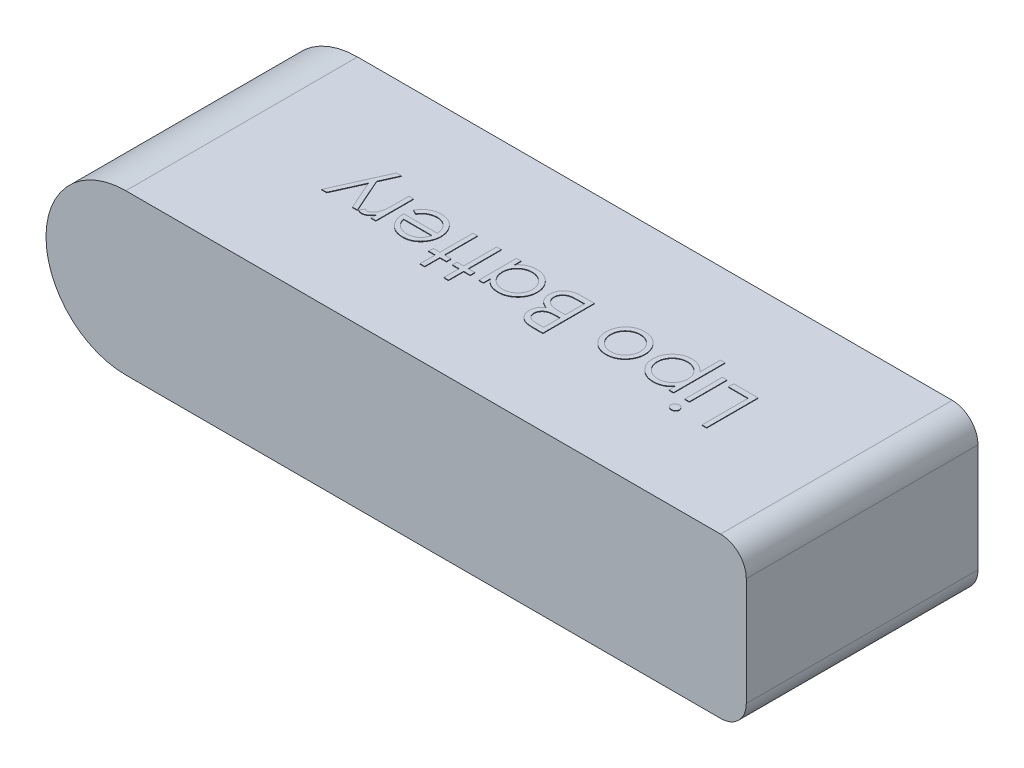
from build123d import *

# Parameters (mm, degrees)
BOSS_EXTRUDE1_DEPTH = 45
FILLET1_R           = 5
SKETCH2_W           = 0.897435898
SKETCH2_H           = 7.307692308
BOSS_EXTRUDE2_DEPTH = 0.1


with BuildPart() as part:
    # Sketch1 → Boss-Extrude1 (new body)
    with BuildSketch(Plane.XY):
        with BuildLine():
            ThreePointArc((0, 15.5), (-15.5, 0), (0, -15.5))
            Line((0, -15.5), (120.5, -15.5))
            Line((120.5, -15.5), (120.5, 15.5))
            Line((120.5, 15.5), (0, 15.5))
        make_face()
    extrude(amount=BOSS_EXTRUDE1_DEPTH)

    # Fillet1
    fillet1_edges = [part.edges().sort_by_distance(p)[0] for p in [
        (120.5, 15.5, 22.5),
        (120.5, -15.5, 22.5),
    ]]
    fillet(fillet1_edges, radius=FILLET1_R)

    # Sketch2 → Boss-Extrude2 (add)
    with BuildSketch(Plane(origin=(0, 15.5, 0), x_dir=(-1, 0, 0), z_dir=(0, 1, 0))):
        Polygon((-96.332346914, 28.540798955), (-95.434911017, 28.540798955), (-95.434911017, 19.566439981), (-91.588757171, 19.566439981), (-91.588757171, 18.540798955), (-96.332346914, 18.540798955), align=None)
        with BuildLine():
            add(Edge.make_bspline(
                [(-89.86199435, 28.92541434), (-89.806304876, 28.922831047), (-89.697254191, 28.917772465), (-89.539559141, 28.874453959), (-89.395967678, 28.801026286), (-89.268602726, 28.702512912), (-89.159311622, 28.586657359), (-89.082795306, 28.451626021), (-89.033617032, 28.305744196), (-89.027678302, 28.203986798), (-89.024654606, 28.152177161)],
                knots=[0, 0, 0, 0, 0.000166856, 0.000326737, 0.000486202, 0.000647669, 0.000807887, 0.000960447, 0.001109951, 0.001265028, 0.001265028, 0.001265028, 0.001265028], degree=3))
            add(Edge.make_bspline(
                [(-89.024654606, 28.152177161), (-89.027746492, 28.101712437), (-89.033858783, 28.001949651), (-89.082757321, 27.858596874), (-89.159963715, 27.725441779), (-89.268532645, 27.609811178), (-89.395986248, 27.511352264), (-89.539554207, 27.437910152), (-89.697255489, 27.394595474), (-89.806305315, 27.389536364), (-89.86199435, 27.386952802)],
                knots=[0, 0, 0, 0, 0.000151093, 0.000298692, 0.000449519, 0.000609738, 0.000771204, 0.00093067, 0.00109055, 0.001257407, 0.001257407, 0.001257407, 0.001257407], degree=3))
            add(Edge.make_bspline(
                [(-89.86199435, 27.386952802), (-89.917046565, 27.389437717), (-90.024198508, 27.394274279), (-90.179532343, 27.438760044), (-90.321899456, 27.511377395), (-90.449512806, 27.609166496), (-90.555884787, 27.726151916), (-90.633308574, 27.858515613), (-90.682094179, 28.001970341), (-90.688221689, 28.101719387), (-90.691321273, 28.152177161)],
                knots=[0, 0, 0, 0, 0.00016486, 0.000320879, 0.000480345, 0.000641811, 0.000800684, 0.000951511, 0.001099111, 0.001250203, 0.001250203, 0.001250203, 0.001250203], degree=3))
            add(Edge.make_bspline(
                [(-90.691321273, 28.152177161), (-90.688289597, 28.203979588), (-90.682335194, 28.305722824), (-90.633272005, 28.451708632), (-90.556529697, 28.585941495), (-90.449442373, 28.703157207), (-90.321918201, 28.801001307), (-90.1795275, 28.873604111), (-90.024199788, 28.918093652), (-89.917046999, 28.922929693), (-89.86199435, 28.92541434)],
                knots=[0, 0, 0, 0, 0.000155077, 0.000304581, 0.000457141, 0.000616014, 0.00077748, 0.000936946, 0.001092965, 0.001257825, 0.001257825, 0.001257825, 0.001257825], degree=3))
        make_face()
        with Locations((-89.85798794, 22.194645109)):
            Rectangle(SKETCH2_W, SKETCH2_H)
        with BuildLine():
            Line((-87.229782812, 25.848491263), (-86.332346914, 25.848491263))
            Line((-86.332346914, 25.848491263), (-86.332346914, 24.496327802))
            add(Edge.make_bspline(
                [(-86.332346914, 24.496327802), (-86.237039817, 24.619007041), (-86.051829546, 24.857409592), (-85.732615532, 25.165952817), (-85.395681793, 25.42616797), (-85.032357757, 25.630118064), (-84.648290071, 25.783891813), (-84.245054878, 25.897547384), (-83.819229836, 25.964523025), (-83.528097114, 25.972584915), (-83.379622555, 25.976696391)],
                knots=[0, 0, 0, 0, 0.000465542, 0.000904687, 0.001327776, 0.001739492, 0.002150169, 0.002566218, 0.002994033, 0.00343929, 0.00343929, 0.00343929, 0.00343929], degree=3))
            add(Edge.make_bspline(
                [(-83.379622555, 25.976696391), (-83.24993226, 25.972944452), (-82.993592579, 25.965528546), (-82.616269068, 25.915319818), (-82.25291083, 25.829269269), (-81.905573533, 25.705266653), (-81.570536203, 25.551965311), (-81.252758775, 25.358488066), (-80.947291474, 25.134470378), (-80.661816648, 24.876664233), (-80.398041312, 24.597726329), (-80.169909366, 24.297662603), (-79.973132496, 23.986340927), (-79.814074506, 23.65893495), (-79.689479228, 23.318022864), (-79.600865863, 22.962227319), (-79.548129739, 22.592867489), (-79.541054163, 22.341716859), (-79.537475119, 22.214677161)],
                knots=[0, 0, 0, 0, 0.00038904, 0.000768958, 0.00113968, 0.001507147, 0.001873712, 0.002243025, 0.002621243, 0.003008526, 0.003395435, 0.003771253, 0.004137539, 0.004498588, 0.004861074, 0.005224489, 0.005596741, 0.005977776, 0.005977776, 0.005977776, 0.005977776], degree=3))
            add(Edge.make_bspline(
                [(-79.537475119, 22.214677161), (-79.540976507, 22.084956279), (-79.547881748, 21.82912798), (-79.601438907, 21.45345056), (-79.687029976, 21.092058063), (-79.810053357, 20.745551596), (-79.969029038, 20.414169735), (-80.162470639, 20.09815146), (-80.390717688, 19.797598023), (-80.651578053, 19.516589737), (-80.934586441, 19.257734557), (-81.237093554, 19.031340073), (-81.55440477, 18.841221857), (-81.884896676, 18.682413402), (-82.2313985, 18.562721447), (-82.59229358, 18.476384874), (-82.967385427, 18.423143458), (-83.222531575, 18.416137336), (-83.351577683, 18.412593827)],
                knots=[0, 0, 0, 0, 0.00038904, 0.000767243, 0.001136017, 0.001501595, 0.001868056, 0.002236695, 0.002611299, 0.002998312, 0.003385449, 0.00376045, 0.004129763, 0.004493553, 0.004858467, 0.005227242, 0.005605444, 0.005992483, 0.005992483, 0.005992483, 0.005992483], degree=3))
            add(Edge.make_bspline(
                [(-83.351577683, 18.412593827), (-83.496799318, 18.416293278), (-83.783654621, 18.423600777), (-84.203076536, 18.497656235), (-84.606724684, 18.608333194), (-84.990127041, 18.770330318), (-85.356320791, 18.976774649), (-85.703234522, 19.228518095), (-86.032710958, 19.525034166), (-86.231021693, 19.749982212), (-86.332346914, 19.864917545)],
                knots=[0, 0, 0, 0, 0.000435254, 0.000859754, 0.001273875, 0.001688693, 0.002104883, 0.002532434, 0.002972128, 0.003431495, 0.003431495, 0.003431495, 0.003431495], degree=3))
            Line((-86.332346914, 19.864917545), (-86.332346914, 15.848491263))
            Line((-86.332346914, 15.848491263), (-87.229782812, 15.848491263))
            Line((-87.229782812, 15.848491263), (-87.229782812, 25.848491263))
        make_face()
        with BuildLine():
            add(Edge.make_bspline(
                [(-83.387635376, 25.079260494), (-83.489291269, 25.077431185), (-83.689425519, 25.073829746), (-83.982774716, 25.031047036), (-84.265333081, 24.968939204), (-84.534252943, 24.874905203), (-84.792111847, 24.759480022), (-85.036923746, 24.615245705), (-85.268516796, 24.444811402), (-85.486308312, 24.251441848), (-85.683060579, 24.038371311), (-85.857240373, 23.81097757), (-86.003546959, 23.5695486), (-86.124981302, 23.316333279), (-86.217390682, 23.04934675), (-86.282978452, 22.770109571), (-86.324208032, 22.478316106), (-86.329604995, 22.279584659), (-86.332346914, 22.178619468)],
                knots=[0, 0, 0, 0, 0.000304724, 0.000599924, 0.000887605, 0.001171411, 0.001452916, 0.001733951, 0.00202203, 0.002314319, 0.002606334, 0.002890796, 0.003172166, 0.003451726, 0.003731746, 0.004017931, 0.004311145, 0.004613954, 0.004613954, 0.004613954, 0.004613954], degree=3))
            add(Edge.make_bspline(
                [(-86.332346914, 22.178619468), (-86.327801611, 22.046082004), (-86.318896977, 21.786429886), (-86.246504497, 21.407046681), (-86.128689457, 21.048041951), (-85.961464561, 20.712438988), (-85.750185777, 20.403916602), (-85.495619616, 20.127657726), (-85.20006947, 19.885398895), (-84.868448923, 19.68133817), (-84.512957121, 19.51565798), (-84.142140229, 19.39704595), (-83.761097712, 19.323982441), (-83.503473942, 19.314705815), (-83.37361294, 19.310029725)],
                knots=[0, 0, 0, 0, 0.000397362, 0.000778467, 0.001154114, 0.001527689, 0.001899412, 0.002272272, 0.002650851, 0.003042195, 0.003437441, 0.003824516, 0.004207589, 0.004596954, 0.004596954, 0.004596954, 0.004596954], degree=3))
            add(Edge.make_bspline(
                [(-83.37361294, 19.310029725), (-83.246367888, 19.314476516), (-82.993809337, 19.323302597), (-82.62192899, 19.399697418), (-82.260527166, 19.516397488), (-81.917155245, 19.68656765), (-81.594802422, 19.895110673), (-81.303712269, 20.145282196), (-81.049406802, 20.435253462), (-80.832651502, 20.758134899), (-80.657990115, 21.104350281), (-80.526760858, 21.46258282), (-80.451022078, 21.831569743), (-80.440288396, 22.080134637), (-80.434911017, 22.204661135)],
                knots=[0, 0, 0, 0, 0.000381367, 0.000756946, 0.001134495, 0.00151794, 0.001902983, 0.002283655, 0.002665449, 0.003056587, 0.003447186, 0.003826105, 0.004198146, 0.004571651, 0.004571651, 0.004571651, 0.004571651], degree=3))
            add(Edge.make_bspline(
                [(-80.434911017, 22.204661135), (-80.439067399, 22.329961104), (-80.447347781, 22.579584829), (-80.528910746, 22.947478837), (-80.651482111, 23.307158769), (-80.83022226, 23.648646054), (-81.042225887, 23.970857718), (-81.298645878, 24.255297373), (-81.586120725, 24.504356438), (-81.908089765, 24.710114752), (-82.253633838, 24.873787594), (-82.61739074, 24.993455134), (-82.997515318, 25.065380133), (-83.256451474, 25.074593008), (-83.387635376, 25.079260494)],
                knots=[0, 0, 0, 0, 0.00037537, 0.000747815, 0.001125397, 0.001512425, 0.001900784, 0.00227958, 0.002657427, 0.00303861, 0.003422123, 0.003801576, 0.00418465, 0.004578013, 0.004578013, 0.004578013, 0.004578013], degree=3))
        make_face(mode=Mode.SUBTRACT)
        with BuildLine():
            add(Edge.make_bspline(
                [(-74.212955889, 25.976696391), (-74.075837966, 25.973776702), (-73.80698323, 25.968051906), (-73.413246413, 25.90686629), (-73.037403168, 25.813302391), (-72.678014047, 25.683955071), (-72.339681775, 25.51057807), (-72.01747822, 25.303694381), (-71.712286766, 25.058601256), (-71.529363825, 24.869006775), (-71.436513581, 24.772770109)],
                knots=[0, 0, 0, 0, 0.000411053, 0.000805974, 0.001192224, 0.001571824, 0.001948986, 0.002330169, 0.002719044, 0.00311991, 0.00311991, 0.00311991, 0.00311991], degree=3))
            add(Edge.make_bspline(
                [(-71.436513581, 24.772770109), (-71.356565141, 24.68073015), (-71.198215483, 24.498431458), (-70.995170572, 24.202843992), (-70.820251829, 23.896729419), (-70.68007194, 23.576022771), (-70.569543301, 23.243523711), (-70.491069883, 22.898089393), (-70.444392926, 22.540482687), (-70.438098735, 22.297614578), (-70.434911017, 22.174613058)],
                knots=[0, 0, 0, 0, 0.00036549, 0.000723907, 0.001073752, 0.001421762, 0.001772071, 0.002123416, 0.00248295, 0.002851888, 0.002851888, 0.002851888, 0.002851888], degree=3))
            add(Edge.make_bspline(
                [(-70.434911017, 22.174613058), (-70.437714838, 22.050898607), (-70.443255318, 21.806433084), (-70.495665651, 21.446377753), (-70.577183039, 21.097249688), (-70.693845434, 20.760510563), (-70.843440032, 20.435131056), (-71.025984853, 20.122532344), (-71.242760902, 19.822097677), (-71.488486608, 19.53637814), (-71.760063397, 19.273046097), (-72.054680963, 19.043536756), (-72.366549631, 18.846903829), (-72.699816355, 18.68851407), (-73.051437746, 18.563629212), (-73.422172226, 18.475914879), (-73.811443855, 18.422881497), (-74.077235916, 18.416071288), (-74.212955889, 18.412593827)],
                knots=[0, 0, 0, 0, 0.000370939, 0.000732993, 0.001089147, 0.001445177, 0.001800129, 0.002161911, 0.002529378, 0.00291005, 0.003291149, 0.003662213, 0.004028498, 0.004394959, 0.004766871, 0.005145852, 0.005535963, 0.005943014, 0.005943014, 0.005943014, 0.005943014], degree=3))
            add(Edge.make_bspline(
                [(-74.212955889, 18.412593827), (-74.349340801, 18.416082959), (-74.616457543, 18.422916601), (-75.007103206, 18.475708837), (-75.378502117, 18.563588787), (-75.730583827, 18.688924481), (-76.06528339, 18.846908891), (-76.378959096, 19.04294229), (-76.673815997, 19.273114162), (-76.945450238, 19.536359697), (-77.191160539, 19.822102429), (-77.407940563, 20.122531111), (-77.590484352, 20.435131378), (-77.74007922, 20.760510477), (-77.856741543, 21.097249711), (-77.938258951, 21.446377747), (-77.990669278, 21.806433085), (-77.99620976, 22.050898608), (-77.999013581, 22.174613058)],
                knots=[0, 0, 0, 0, 0.000409051, 0.000801148, 0.00118013, 0.001552041, 0.00192031, 0.002288295, 0.002659358, 0.003040457, 0.003421129, 0.003788596, 0.004150379, 0.00450533, 0.00486136, 0.005217514, 0.005579568, 0.005950508, 0.005950508, 0.005950508, 0.005950508], degree=3))
            add(Edge.make_bspline(
                [(-77.999013581, 22.174613058), (-77.995804123, 22.296946046), (-77.989449947, 22.539144339), (-77.942819921, 22.896078798), (-77.864652617, 23.240928481), (-77.753991484, 23.572144127), (-77.61251951, 23.891445372), (-77.440058688, 24.198316318), (-77.234942595, 24.492567177), (-77.077222733, 24.674630262), (-76.997411017, 24.766760494)],
                knots=[0, 0, 0, 0, 0.000366937, 0.000726472, 0.001077816, 0.001426224, 0.001772402, 0.002123991, 0.002480764, 0.002846254, 0.002846254, 0.002846254, 0.002846254], degree=3))
            add(Edge.make_bspline(
                [(-76.997411017, 24.766760494), (-76.904700757, 24.863831749), (-76.722369717, 25.054739452), (-76.415659066, 25.299118093), (-76.094248149, 25.510306875), (-75.752176931, 25.680238919), (-75.393083052, 25.814063256), (-75.015313787, 25.907107584), (-74.620240886, 25.967831456), (-74.35007054, 25.973711964), (-74.212955889, 25.976696391)],
                knots=[0, 0, 0, 0, 0.00040228, 0.000791155, 0.001173426, 0.001554167, 0.001934459, 0.002320709, 0.002719594, 0.003130646, 0.003130646, 0.003130646, 0.003130646], degree=3))
        make_face()
        with BuildLine():
            add(Edge.make_bspline(
                [(-74.216962299, 25.079260494), (-74.313926903, 25.076504518), (-74.505352984, 25.07106371), (-74.787123226, 25.029681125), (-75.058380809, 24.964116828), (-75.319640364, 24.870962382), (-75.570020856, 24.750679813), (-75.809762006, 24.602941641), (-76.039568977, 24.429704623), (-76.254946301, 24.231239847), (-76.45261005, 24.01444272), (-76.625404269, 23.783447408), (-76.772333144, 23.542000705), (-76.894733599, 23.28985153), (-76.985896993, 23.024444633), (-77.052105629, 22.748785687), (-77.093449173, 22.462313068), (-77.098838826, 22.267567302), (-77.101577683, 22.168603443)],
                knots=[0, 0, 0, 0, 0.000290803, 0.000574099, 0.000852494, 0.001126845, 0.001404598, 0.001684259, 0.001970318, 0.002266636, 0.002561605, 0.002849265, 0.003130635, 0.003408388, 0.003688407, 0.003970696, 0.004257958, 0.004554764, 0.004554764, 0.004554764, 0.004554764], degree=3))
            add(Edge.make_bspline(
                [(-77.101577683, 22.168603443), (-77.096986759, 22.040740508), (-77.087874632, 21.786956492), (-77.013773956, 21.413210427), (-76.889813157, 21.054405136), (-76.722420929, 20.712644033), (-76.512688875, 20.396437524), (-76.265582971, 20.114518997), (-75.983755255, 19.871130965), (-75.670565255, 19.669185692), (-75.332410061, 19.508729247), (-74.974534858, 19.395017888), (-74.601275732, 19.321098766), (-74.346187928, 19.313751697), (-74.216962299, 19.310029725)],
                knots=[0, 0, 0, 0, 0.000383367, 0.000760911, 0.001137838, 0.001519484, 0.001899508, 0.002272819, 0.002640674, 0.003012952, 0.003387508, 0.003760008, 0.004137175, 0.004524421, 0.004524421, 0.004524421, 0.004524421], degree=3))
            add(Edge.make_bspline(
                [(-74.216962299, 19.310029725), (-74.087744102, 19.313773383), (-73.83267097, 19.321163259), (-73.459930465, 19.394645601), (-73.103033403, 19.509227489), (-72.765229438, 19.669005232), (-72.452182, 19.871897845), (-72.168327368, 20.113144637), (-71.923331336, 20.397184212), (-71.71380675, 20.713062866), (-71.5436732, 21.0538753), (-71.420292623, 21.41327665), (-71.346013806, 21.786939627), (-71.336925724, 22.040734858), (-71.332346914, 22.168603443)],
                knots=[0, 0, 0, 0, 0.000387246, 0.000764413, 0.001135006, 0.001509562, 0.001881841, 0.002251213, 0.002623206, 0.003003229, 0.003385763, 0.00376269, 0.004140235, 0.004523601, 0.004523601, 0.004523601, 0.004523601], degree=3))
            add(Edge.make_bspline(
                [(-71.332346914, 22.168603443), (-71.335084829, 22.267567893), (-71.340472626, 22.462314824), (-71.381829667, 22.748778977), (-71.447988352, 23.024469253), (-71.53933583, 23.289760691), (-71.661204441, 23.54265356), (-71.810966707, 23.782738495), (-71.983055351, 24.015242912), (-72.183104267, 24.230539029), (-72.398256776, 24.42978199), (-72.628156885, 24.603008817), (-72.867542538, 24.750030519), (-73.117195631, 24.871991206), (-73.378488682, 24.963269321), (-73.649366194, 25.030059697), (-73.929934222, 25.07088883), (-74.120674345, 25.076452091), (-74.216962299, 25.079260494)],
                knots=[0, 0, 0, 0, 0.000296806, 0.000584068, 0.000866357, 0.001146376, 0.001424129, 0.001706545, 0.001994206, 0.002290525, 0.002586843, 0.002872902, 0.003152563, 0.003428511, 0.00370475, 0.0039812, 0.004264496, 0.004553298, 0.004553298, 0.004553298, 0.004553298], degree=3))
        make_face(mode=Mode.SUBTRACT)
        with BuildLine():
            Line((-64.537475119, 28.540798955), (-62.586353324, 28.540798955))
            add(Edge.make_bspline(
                [(-62.586353324, 28.540798955), (-62.490843387, 28.540296811), (-62.305721357, 28.539323531), (-62.036522952, 28.524228871), (-61.784383493, 28.503646957), (-61.549229858, 28.470989549), (-61.331170708, 28.431584472), (-61.129548887, 28.383864997), (-60.945005538, 28.326646101), (-60.724683434, 28.235656726), (-60.473481546, 28.100447674), (-60.201486138, 27.900651773), (-59.968902597, 27.656273307), (-59.768370262, 27.380608578), (-59.608938492, 27.077363515), (-59.493597642, 26.753765833), (-59.420575141, 26.413989428), (-59.413065329, 26.180723205), (-59.409269991, 26.062834212)],
                knots=[0, 0, 0, 0, 0.000286486, 0.000555282, 0.000808646, 0.001045202, 0.001267197, 0.001473206, 0.00166644, 0.001846115, 0.002187607, 0.002519741, 0.002854078, 0.00319547, 0.003539555, 0.003877913, 0.004223639, 0.004576891, 0.004576891, 0.004576891, 0.004576891], degree=3))
            add(Edge.make_bspline(
                [(-59.409269991, 26.062834212), (-59.412393472, 25.952398338), (-59.418531408, 25.735381433), (-59.477225006, 25.417969692), (-59.56911263, 25.115823352), (-59.696841913, 24.830045108), (-59.862847617, 24.567091928), (-60.05958567, 24.324842596), (-60.296947963, 24.113553862), (-60.474785791, 23.995431283), (-60.56511935, 23.935430366)],
                knots=[0, 0, 0, 0, 0.00033102, 0.000650486, 0.000964778, 0.00127679, 0.001586381, 0.001895193, 0.002210111, 0.002535211, 0.002535211, 0.002535211, 0.002535211], degree=3))
            add(Edge.make_bspline(
                [(-60.56511935, 23.935430366), (-60.451518128, 23.891816083), (-60.23417085, 23.808371156), (-59.935067957, 23.660841259), (-59.6773684, 23.500378086), (-59.45909084, 23.325144229), (-59.272411826, 23.136261912), (-59.109403422, 22.930961586), (-58.970313781, 22.706565135), (-58.851134, 22.465412177), (-58.758137554, 22.209965124), (-58.688492113, 21.94262005), (-58.648585115, 21.664335606), (-58.64290614, 21.474948808), (-58.640039222, 21.379340622)],
                knots=[0, 0, 0, 0, 0.000364919, 0.00069818, 0.000998855, 0.001273849, 0.001535901, 0.001794004, 0.002058579, 0.002326447, 0.002599596, 0.00287265, 0.003153963, 0.003440765, 0.003440765, 0.003440765, 0.003440765], degree=3))
            add(Edge.make_bspline(
                [(-58.640039222, 21.379340622), (-58.64283021, 21.281720987), (-58.648321559, 21.089651621), (-58.688835764, 20.807494094), (-58.757433212, 20.53785139), (-58.851922202, 20.278979439), (-58.975243101, 20.031379055), (-59.125322999, 19.794769729), (-59.304270324, 19.571528784), (-59.504449949, 19.359175576), (-59.730913222, 19.16823904), (-59.97524395, 18.998194164), (-60.24051915, 18.858348272), (-60.52238199, 18.740873925), (-60.823994322, 18.651139072), (-61.144001772, 18.58836029), (-61.482128348, 18.546060184), (-61.714156209, 18.542582456), (-61.833148196, 18.540798955)],
                knots=[0, 0, 0, 0, 0.000292804, 0.0005761, 0.000853035, 0.001126185, 0.001401215, 0.001681299, 0.001965055, 0.002258352, 0.002555374, 0.002852092, 0.003149627, 0.00345319, 0.003766901, 0.004091797, 0.004430712, 0.004787485, 0.004787485, 0.004787485, 0.004787485], degree=3))
            Line((-61.833148196, 18.540798955), (-64.537475119, 18.540798955))
            Line((-64.537475119, 18.540798955), (-64.537475119, 28.540798955))
        make_face()
        with BuildLine():
            Line((-63.640039222, 27.51515793), (-63.640039222, 24.310029725))
            Line((-63.640039222, 24.310029725), (-63.037074478, 24.310029725))
            add(Edge.make_bspline(
                [(-63.037074478, 24.310029725), (-62.948935063, 24.311172362), (-62.778631751, 24.31338017), (-62.532003475, 24.319704504), (-62.303074851, 24.3374132), (-62.092241043, 24.355116805), (-61.89983406, 24.383901342), (-61.72628017, 24.41816455), (-61.568855607, 24.454401422), (-61.387314049, 24.516028527), (-61.181391339, 24.607107599), (-60.961868184, 24.748455702), (-60.768341128, 24.916810997), (-60.604920592, 25.111070888), (-60.471173533, 25.324974276), (-60.378277204, 25.55510822), (-60.315284963, 25.795737169), (-60.309594874, 25.960932177), (-60.306705889, 26.044805366)],
                knots=[0, 0, 0, 0, 0.000264453, 0.000510978, 0.000739905, 0.000953187, 0.001145547, 0.001323122, 0.001483941, 0.001629639, 0.001897717, 0.002157215, 0.002409921, 0.002664359, 0.002916198, 0.003163211, 0.003406623, 0.003657671, 0.003657671, 0.003657671, 0.003657671], degree=3))
            add(Edge.make_bspline(
                [(-60.306705889, 26.044805366), (-60.30820926, 26.10030757), (-60.311158289, 26.209181205), (-60.335310582, 26.367893645), (-60.376360795, 26.517161509), (-60.429087347, 26.659030396), (-60.502769314, 26.789064254), (-60.589522067, 26.911759099), (-60.694338325, 27.02293658), (-60.813644932, 27.126849432), (-60.950812426, 27.218976655), (-61.105758974, 27.299664549), (-61.280580909, 27.364638197), (-61.472331923, 27.42154149), (-61.683963601, 27.461508044), (-61.913033754, 27.494803437), (-62.161418666, 27.511754128), (-62.333261816, 27.513998022), (-62.422090504, 27.51515793)],
                knots=[0, 0, 0, 0, 0.000166459, 0.000326527, 0.000480083, 0.000630377, 0.000779222, 0.000927093, 0.001080178, 0.001236402, 0.001400861, 0.001574678, 0.001759202, 0.001959522, 0.002174024, 0.002404628, 0.002653679, 0.002920173, 0.002920173, 0.002920173, 0.002920173], degree=3))
            Line((-62.422090504, 27.51515793), (-63.640039222, 27.51515793))
        make_face(mode=Mode.SUBTRACT)
        with BuildLine():
            Line((-63.640039222, 23.284388699), (-63.640039222, 19.566439981))
            Line((-63.640039222, 19.566439981), (-62.36199435, 19.566439981))
            add(Edge.make_bspline(
                [(-62.36199435, 19.566439981), (-62.270511705, 19.567536402), (-62.094190966, 19.569649609), (-61.839616023, 19.576548337), (-61.603664297, 19.592240553), (-61.387412481, 19.616942981), (-61.188525474, 19.64373855), (-61.009389179, 19.679770781), (-60.848551484, 19.721053525), (-60.662053461, 19.784865446), (-60.452043438, 19.88399822), (-60.225726705, 20.033467438), (-60.024508939, 20.211534032), (-59.85363677, 20.417622358), (-59.71359966, 20.641711864), (-59.611726931, 20.879270006), (-59.548895912, 21.126371513), (-59.541289714, 21.294847835), (-59.537475119, 21.379340622)],
                knots=[0, 0, 0, 0, 0.000274468, 0.000529002, 0.000763924, 0.000983592, 0.0011819, 0.001365758, 0.001531444, 0.001679681, 0.001956573, 0.002225481, 0.00249082, 0.002759616, 0.003025892, 0.003280771, 0.003532443, 0.00378564, 0.00378564, 0.00378564, 0.00378564], degree=3))
            add(Edge.make_bspline(
                [(-59.537475119, 21.379340622), (-59.538263989, 21.432178738), (-59.539829003, 21.537002686), (-59.56343076, 21.691047883), (-59.597756103, 21.840264664), (-59.642131628, 21.985058209), (-59.706758677, 22.122810712), (-59.782205948, 22.256246597), (-59.870667096, 22.385542252), (-60.00850757, 22.549005834), (-60.208998954, 22.737340156), (-60.493875455, 22.92173302), (-60.817796307, 23.07044104), (-61.052732001, 23.133582401), (-61.174093709, 23.166199596)],
                knots=[0, 0, 0, 0, 0.000158367, 0.00031418, 0.000466279, 0.00061769, 0.000767395, 0.000921694, 0.001077275, 0.001236551, 0.001562539, 0.001898122, 0.002250419, 0.002626872, 0.002626872, 0.002626872, 0.002626872], degree=3))
            add(Edge.make_bspline(
                [(-61.174093709, 23.166199596), (-61.222748269, 23.176071265), (-61.32824139, 23.197475078), (-61.500263048, 23.220068517), (-61.696651245, 23.240197259), (-61.917859465, 23.255086281), (-62.164167583, 23.270476405), (-62.436101636, 23.276461609), (-62.732551107, 23.283602352), (-62.938243599, 23.284119878), (-63.045087299, 23.284388699)],
                knots=[0, 0, 0, 0, 0.000148899, 0.000322844, 0.000520177, 0.000741112, 0.000987905, 0.001260458, 0.001556994, 0.001877513, 0.001877513, 0.001877513, 0.001877513], degree=3))
            Line((-63.045087299, 23.284388699), (-63.640039222, 23.284388699))
        make_face(mode=Mode.SUBTRACT)
        with BuildLine():
            Line((-49.409269991, 25.848491263), (-49.409269991, 18.540798955))
            Line((-49.409269991, 18.540798955), (-50.306705889, 18.540798955))
            Line((-50.306705889, 18.540798955), (-50.306705889, 19.804821391))
            add(Edge.make_bspline(
                [(-50.306705889, 19.804821391), (-50.407902433, 19.690422551), (-50.605388763, 19.467171777), (-50.935220528, 19.175508427), (-51.284843894, 18.934427508), (-51.652561954, 18.739713463), (-52.038042649, 18.593450445), (-52.44043147, 18.489489991), (-52.859892558, 18.422650462), (-53.146327858, 18.415976113), (-53.29148153, 18.412593827)],
                knots=[0, 0, 0, 0, 0.000457893, 0.000893585, 0.001316996, 0.001729189, 0.002138795, 0.002550818, 0.002974366, 0.003409523, 0.003409523, 0.003409523, 0.003409523], degree=3))
            add(Edge.make_bspline(
                [(-53.29148153, 18.412593827), (-53.420532826, 18.416097748), (-53.675027697, 18.423007635), (-54.049396489, 18.476614217), (-54.409660059, 18.562701707), (-54.756158838, 18.682418534), (-55.086650682, 18.841220882), (-55.403965244, 19.031338733), (-55.70645865, 19.257741105), (-55.98952019, 19.516564043), (-56.250183048, 19.797692578), (-56.478929541, 20.097536998), (-56.669652626, 20.414800723), (-56.829138571, 20.745466877), (-56.95198527, 21.092080933), (-57.037624225, 21.45344427), (-57.091168358, 21.829129623), (-57.098075389, 22.084956832), (-57.101577683, 22.214677161)],
                knots=[0, 0, 0, 0, 0.000387039, 0.000763257, 0.001132032, 0.001496946, 0.001860736, 0.002230049, 0.00260505, 0.002992187, 0.0033792, 0.003753804, 0.004121402, 0.004487863, 0.004853441, 0.005222215, 0.005600418, 0.005989458, 0.005989458, 0.005989458, 0.005989458], degree=3))
            add(Edge.make_bspline(
                [(-57.101577683, 22.214677161), (-57.097997765, 22.341716314), (-57.09092046, 22.592865866), (-57.038196975, 22.962233574), (-56.94953695, 23.318000034), (-56.825114528, 23.659019872), (-56.665566085, 23.985705729), (-56.471485837, 24.298288658), (-56.242859766, 24.597629793), (-55.97928146, 24.876690441), (-55.693753546, 25.134463625), (-55.388300029, 25.358489469), (-55.070519225, 25.55196618), (-54.735482052, 25.705261827), (-54.388147467, 25.82928784), (-54.025423336, 25.91509632), (-53.648818826, 25.965660095), (-53.393131705, 25.972982278), (-53.263436658, 25.976696391)],
                knots=[0, 0, 0, 0, 0.000381036, 0.000753287, 0.001116702, 0.001479188, 0.001840237, 0.002205464, 0.002581283, 0.002968192, 0.003355474, 0.003733693, 0.004103006, 0.00446957, 0.004837037, 0.00520776, 0.005585692, 0.005974732, 0.005974732, 0.005974732, 0.005974732], degree=3))
            add(Edge.make_bspline(
                [(-53.263436658, 25.976696391), (-53.114294203, 25.97258853), (-52.821832889, 25.964533207), (-52.394038577, 25.897496843), (-51.989340069, 25.78424408), (-51.604613348, 25.630194086), (-51.24123996, 25.425483431), (-50.902660004, 25.167254971), (-50.585330052, 24.857137294), (-50.401386362, 24.618936024), (-50.306705889, 24.496327802)],
                knots=[0, 0, 0, 0, 0.000447258, 0.000877052, 0.001295031, 0.001705707, 0.002117423, 0.002542108, 0.00297982, 0.003444098, 0.003444098, 0.003444098, 0.003444098], degree=3))
            Line((-50.306705889, 24.496327802), (-50.306705889, 25.848491263))
            Line((-50.306705889, 25.848491263), (-49.409269991, 25.848491263))
        make_face()
        with BuildLine():
            add(Edge.make_bspline(
                [(-53.251417427, 25.079260494), (-53.382601249, 25.074592958), (-53.641537249, 25.065379983), (-54.02166297, 24.993455711), (-54.385415581, 24.873785442), (-54.730975793, 24.710122867), (-55.052884984, 24.504326476), (-55.340581186, 24.255408238), (-55.596417476, 23.970159627), (-55.811583945, 23.649867883), (-55.986985365, 23.306501908), (-56.110319742, 22.947574942), (-56.191660449, 22.579560721), (-56.199970507, 22.329953047), (-56.204141786, 22.204661135)],
                knots=[0, 0, 0, 0, 0.000393363, 0.000776437, 0.00115589, 0.001539403, 0.001920586, 0.002298433, 0.002677229, 0.003066707, 0.003452827, 0.003830409, 0.004202854, 0.004578224, 0.004578224, 0.004578224, 0.004578224], degree=3))
            add(Edge.make_bspline(
                [(-56.204141786, 22.204661135), (-56.198813519, 22.080117972), (-56.188177871, 21.831519812), (-56.111747316, 21.463003878), (-55.983519106, 21.10399233), (-55.808541784, 20.757532348), (-55.589437142, 20.43586349), (-55.335469563, 20.145177425), (-55.044183045, 19.895207173), (-54.721533025, 19.685956963), (-54.376938824, 19.516921189), (-54.014556162, 19.399305076), (-53.641197196, 19.32336856), (-53.387333385, 19.314498626), (-53.259430247, 19.310029725)],
                knots=[0, 0, 0, 0, 0.000373505, 0.000745546, 0.001123791, 0.001514391, 0.001906651, 0.002288444, 0.002669116, 0.003054159, 0.003439405, 0.003816955, 0.004194499, 0.004577866, 0.004577866, 0.004577866, 0.004577866], degree=3))
            add(Edge.make_bspline(
                [(-53.259430247, 19.310029725), (-53.129583097, 19.314772479), (-52.871329992, 19.324205346), (-52.490076541, 19.396437533), (-52.120090933, 19.515776957), (-51.766413138, 19.681203033), (-51.436938478, 19.88622405), (-51.141230256, 20.12624431), (-50.891184632, 20.405396265), (-50.679205747, 20.71218613), (-50.512990271, 21.04850612), (-50.391915816, 21.406603808), (-50.320333228, 21.78649166), (-50.311311144, 22.04610288), (-50.306705889, 22.178619468)],
                knots=[0, 0, 0, 0, 0.000389365, 0.000774407, 0.001159575, 0.001553005, 0.001942648, 0.002321227, 0.002691387, 0.003063109, 0.003436684, 0.003812967, 0.004194071, 0.004591434, 0.004591434, 0.004591434, 0.004591434], degree=3))
            add(Edge.make_bspline(
                [(-50.306705889, 22.178619468), (-50.309447764, 22.279584698), (-50.314844642, 22.478316222), (-50.356074841, 22.770109129), (-50.421660345, 23.049348347), (-50.514077974, 23.316327458), (-50.635481643, 23.569570359), (-50.781903832, 23.810895389), (-50.955919402, 24.039047421), (-51.154727105, 24.250884767), (-51.37234197, 24.44410323), (-51.602612086, 24.61657249), (-51.848265649, 24.758254697), (-52.105171468, 24.875515473), (-52.373775281, 24.96882733), (-52.656262766, 25.031077884), (-52.9496313, 25.073821658), (-53.149762887, 25.07742846), (-53.251417427, 25.079260494)],
                knots=[0, 0, 0, 0, 0.000302809, 0.000596024, 0.000882209, 0.001162228, 0.001441788, 0.001723158, 0.00200762, 0.002300999, 0.002593289, 0.002879754, 0.003162518, 0.003442201, 0.003726006, 0.004013687, 0.004308887, 0.004613611, 0.004613611, 0.004613611, 0.004613611], degree=3))
        make_face(mode=Mode.SUBTRACT)
        Polygon((-46.460552042, 28.797209212), (-45.563116145, 28.797209212), (-45.563116145, 25.848491263), (-44.281064863, 25.848491263), (-44.281064863, 24.951055366), (-45.563116145, 24.951055366), (-45.563116145, 18.540798955), (-46.460552042, 18.540798955), (-46.460552042, 24.951055366), (-47.742603324, 24.951055366), (-47.742603324, 25.848491263), (-46.460552042, 25.848491263), align=None)
        Polygon((-41.845167427, 28.797209212), (-40.94773153, 28.797209212), (-40.94773153, 25.848491263), (-39.665680247, 25.848491263), (-39.665680247, 24.951055366), (-40.94773153, 24.951055366), (-40.94773153, 18.540798955), (-41.845167427, 18.540798955), (-41.845167427, 24.951055366), (-43.127218709, 24.951055366), (-43.127218709, 25.848491263), (-41.845167427, 25.848491263), align=None)
        with BuildLine():
            Line((-32.129622555, 20.848491263), (-31.332346914, 20.429821391))
            add(Edge.make_bspline(
                [(-31.332346914, 20.429821391), (-31.395880043, 20.317126159), (-31.519490353, 20.097865865), (-31.732063919, 19.796631978), (-31.954898412, 19.525638504), (-32.198052606, 19.292125207), (-32.454251689, 19.088549821), (-32.724916417, 18.91044175), (-33.011455896, 18.758674549), (-33.313883681, 18.630810184), (-33.634739542, 18.532497344), (-33.974801017, 18.463056712), (-34.334719575, 18.420133088), (-34.581422946, 18.415146971), (-34.707747555, 18.412593827)],
                knots=[0, 0, 0, 0, 0.000387883, 0.000754666, 0.001104511, 0.001438848, 0.001763899, 0.002085037, 0.002409439, 0.002735346, 0.003068638, 0.003414363, 0.003775396, 0.004154261, 0.004154261, 0.004154261, 0.004154261], degree=3))
            add(Edge.make_bspline(
                [(-34.707747555, 18.412593827), (-34.848153205, 18.415871471), (-35.122043953, 18.422265205), (-35.520728945, 18.477386531), (-35.896098711, 18.567307556), (-36.24813215, 18.692923389), (-36.575967157, 18.857001458), (-36.880255314, 19.056885692), (-37.162596816, 19.291549277), (-37.414094557, 19.563024829), (-37.64050565, 19.853544707), (-37.840293707, 20.156275806), (-38.007314939, 20.470456447), (-38.143179539, 20.794086516), (-38.252907725, 21.125126212), (-38.329384021, 21.466587548), (-38.373469016, 21.81754636), (-38.380224574, 22.054967319), (-38.383628965, 22.174613058)],
                knots=[0, 0, 0, 0, 0.000421059, 0.000821365, 0.00120471, 0.001577296, 0.001940119, 0.002301818, 0.002667309, 0.003038599, 0.003409663, 0.003771362, 0.00412534, 0.004475443, 0.004823223, 0.005170217, 0.005523537, 0.005882469, 0.005882469, 0.005882469, 0.005882469], degree=3))
            add(Edge.make_bspline(
                [(-38.383628965, 22.174613058), (-38.380602847, 22.286884002), (-38.374605481, 22.509390187), (-38.336803231, 22.838720314), (-38.269808108, 23.158801607), (-38.177875754, 23.46990003), (-38.059157908, 23.771494698), (-37.913922996, 24.063769166), (-37.741944773, 24.346412423), (-37.609165706, 24.52470709), (-37.542282812, 24.614516904)],
                knots=[0, 0, 0, 0, 0.00033683, 0.000667554, 0.000992851, 0.001316733, 0.001639622, 0.001963924, 0.002294769, 0.002630567, 0.002630567, 0.002630567, 0.002630567], degree=3))
            add(Edge.make_bspline(
                [(-37.542282812, 24.614516904), (-37.451689432, 24.722713676), (-37.273372442, 24.93567982), (-36.971782855, 25.215503608), (-36.645210866, 25.449914394), (-36.297749077, 25.644220497), (-35.925359151, 25.791859489), (-35.533046891, 25.901881152), (-35.116345216, 25.963532612), (-34.831473156, 25.972240708), (-34.685712299, 25.976696391)],
                knots=[0, 0, 0, 0, 0.000423061, 0.00083272, 0.001230229, 0.001626565, 0.002023846, 0.002429172, 0.002846479, 0.003283733, 0.003283733, 0.003283733, 0.003283733], degree=3))
            add(Edge.make_bspline(
                [(-34.685712299, 25.976696391), (-34.535861998, 25.97282768), (-34.241889867, 25.965238151), (-33.813226664, 25.894877198), (-33.407624616, 25.783298471), (-33.025246033, 25.625716212), (-32.666052145, 25.422403207), (-32.332377717, 25.170569374), (-32.018516253, 24.877946268), (-31.835920313, 24.652908527), (-31.743003965, 24.538395109)],
                knots=[0, 0, 0, 0, 0.000449259, 0.000881343, 0.001299322, 0.001708903, 0.002118876, 0.00253394, 0.002960491, 0.003402438, 0.003402438, 0.003402438, 0.003402438], degree=3))
            add(Edge.make_bspline(
                [(-31.743003965, 24.538395109), (-31.679784142, 24.452099162), (-31.553765304, 24.28008168), (-31.395916447, 23.99959266), (-31.258895318, 23.706133819), (-31.149372573, 23.394961542), (-31.060688284, 23.069762741), (-30.996525944, 22.728212614), (-30.958898463, 22.370412867), (-30.951502185, 22.126622708), (-30.94773153, 22.002337417)],
                knots=[0, 0, 0, 0, 0.000320669, 0.000639204, 0.000963655, 0.001291233, 0.001627509, 0.001974035, 0.002332631, 0.002705571, 0.002705571, 0.002705571, 0.002705571], degree=3))
            Line((-30.94773153, 22.002337417), (-37.486193068, 22.002337417))
            add(Edge.make_bspline(
                [(-37.486193068, 22.002337417), (-37.481794192, 21.906050376), (-37.473143981, 21.716705794), (-37.432815001, 21.439646414), (-37.369247076, 21.175722579), (-37.279906897, 20.926913888), (-37.17171591, 20.689970666), (-37.039185291, 20.466650561), (-36.88107228, 20.257970761), (-36.704713138, 20.062064653), (-36.508407152, 19.887605336), (-36.301885017, 19.731457403), (-36.082189117, 19.60058427), (-35.851051735, 19.494356013), (-35.608846635, 19.41119511), (-35.355497506, 19.354429908), (-35.091502888, 19.316409603), (-34.911543648, 19.312181988), (-34.819927042, 19.310029725)],
                knots=[0, 0, 0, 0, 0.000289024, 0.000568355, 0.000838491, 0.001102062, 0.001360196, 0.001618889, 0.001879306, 0.002144494, 0.00240834, 0.002665952, 0.002920178, 0.003173835, 0.003427863, 0.003686866, 0.003951751, 0.004226453, 0.004226453, 0.004226453, 0.004226453], degree=3))
            add(Edge.make_bspline(
                [(-34.819927042, 19.310029725), (-34.730352335, 19.311767029), (-34.552618932, 19.315214175), (-34.287930768, 19.348733921), (-34.027532119, 19.402934708), (-33.772500738, 19.476906108), (-33.528012607, 19.567125686), (-33.301596749, 19.675990993), (-33.093367562, 19.796418841), (-32.898747657, 19.93416077), (-32.709973391, 20.10275559), (-32.522709144, 20.313143364), (-32.321918706, 20.561964872), (-32.196234155, 20.749238204), (-32.129622555, 20.848491263)],
                knots=[0, 0, 0, 0, 0.000268616, 0.000532986, 0.00079896, 0.001065868, 0.001328929, 0.00157981, 0.001818595, 0.002049833, 0.002293879, 0.002576047, 0.002893901, 0.003252318, 0.003252318, 0.003252318, 0.003252318], degree=3))
        make_face()
        with BuildLine():
            add(Edge.make_bspline(
                [(-31.845167427, 22.899773314), (-31.878014926, 23.018810096), (-31.941235787, 23.247917584), (-32.073339685, 23.565177271), (-32.222115516, 23.847142702), (-32.398177606, 24.09165594), (-32.597659679, 24.308808834), (-32.828074486, 24.49857622), (-33.086462754, 24.668340366), (-33.37148887, 24.811633222), (-33.673322541, 24.933604246), (-33.989340233, 25.015390291), (-34.311791055, 25.071417555), (-34.529889016, 25.076635008), (-34.639638581, 25.079260494)],
                knots=[0, 0, 0, 0, 0.000370122, 0.000712365, 0.001028757, 0.0013245, 0.001613684, 0.001910949, 0.002217642, 0.002539267, 0.002866618, 0.003192181, 0.003516898, 0.003845814, 0.003845814, 0.003845814, 0.003845814], degree=3))
            add(Edge.make_bspline(
                [(-34.639638581, 25.079260494), (-34.729208405, 25.077512861), (-34.906269117, 25.074058158), (-35.167129312, 25.04128636), (-35.417642737, 24.987115374), (-35.659657845, 24.912929784), (-35.890003183, 24.814048063), (-36.113416806, 24.698095987), (-36.324217938, 24.556548604), (-36.456050211, 24.448666162), (-36.522651401, 24.39416434)],
                knots=[0, 0, 0, 0, 0.000268616, 0.000530998, 0.000787173, 0.001036812, 0.001289064, 0.001538172, 0.001790965, 0.002049067, 0.002049067, 0.002049067, 0.002049067], degree=3))
            add(Edge.make_bspline(
                [(-36.522651401, 24.39416434), (-36.570346493, 24.351037724), (-36.666869733, 24.263759964), (-36.795842652, 24.113390802), (-36.919329717, 23.951243482), (-37.031711582, 23.771114554), (-37.1347904, 23.575055186), (-37.231247478, 23.364719085), (-37.318065798, 23.138510141), (-37.366911827, 22.980874601), (-37.392042427, 22.899773314)],
                knots=[0, 0, 0, 0, 0.000192725, 0.000390028, 0.000593153, 0.000803795, 0.001026033, 0.001257306, 0.001497632, 0.001752299, 0.001752299, 0.001752299, 0.001752299], degree=3))
            Line((-37.392042427, 22.899773314), (-31.845167427, 22.899773314))
        make_face(mode=Mode.SUBTRACT)
        with BuildLine():
            Line((-29.409269991, 25.848491263), (-28.511834094, 25.848491263))
            Line((-28.511834094, 25.848491263), (-28.511834094, 24.772770109))
            add(Edge.make_bspline(
                [(-28.511834094, 24.772770109), (-28.445580497, 24.872929619), (-28.318871009, 25.064483902), (-28.108262639, 25.317824762), (-27.892538836, 25.527582038), (-27.670666872, 25.694734949), (-27.441015158, 25.819915289), (-27.208623867, 25.911609675), (-26.96983681, 25.965830575), (-26.80937417, 25.973069601), (-26.72898153, 25.976696391)],
                knots=[0, 0, 0, 0, 0.000360065, 0.000688621, 0.000986136, 0.001260976, 0.001519172, 0.001768417, 0.002008509, 0.002249569, 0.002249569, 0.002249569, 0.002249569], degree=3))
            add(Edge.make_bspline(
                [(-26.72898153, 25.976696391), (-26.666620597, 25.973294887), (-26.538308925, 25.96629607), (-26.344072954, 25.917122285), (-26.143948806, 25.83861365), (-26.014970556, 25.764784442), (-25.94773153, 25.72629575)],
                knots=[0, 0, 0, 0, 0.000186986, 0.000384736, 0.000597887, 0.000830025, 0.000830025, 0.000830025, 0.000830025], degree=3))
            Line((-25.94773153, 25.72629575), (-26.440519991, 24.949052161))
            add(Edge.make_bspline(
                [(-26.440519991, 24.949052161), (-26.483688623, 24.968310064), (-26.56563095, 25.004865251), (-26.685501139, 25.048128137), (-26.796019244, 25.073602182), (-26.866429411, 25.077461375), (-26.899253965, 25.079260494)],
                knots=[0, 0, 0, 0, 0.000141775, 0.000269117, 0.000381885, 0.000480369, 0.000480369, 0.000480369, 0.000480369], degree=3))
            add(Edge.make_bspline(
                [(-26.899253965, 25.079260494), (-26.971270347, 25.074460387), (-27.11816289, 25.064669561), (-27.333832888, 24.987701539), (-27.543110618, 24.86334371), (-27.709315367, 24.725426247), (-27.838007519, 24.59243254), (-27.929836734, 24.476294247), (-28.014073154, 24.346069586), (-28.094559498, 24.203984775), (-28.167891767, 24.047613786), (-28.236333679, 23.878518891), (-28.298216145, 23.696504237), (-28.333502557, 23.569697036), (-28.351577683, 23.504741263)],
                knots=[0, 0, 0, 0, 0.000215687, 0.000439938, 0.000678723, 0.000943419, 0.001085096, 0.001233387, 0.001386734, 0.00154998, 0.001722918, 0.001904448, 0.002097027, 0.002299272, 0.002299272, 0.002299272, 0.002299272], degree=3))
            add(Edge.make_bspline(
                [(-28.351577683, 23.504741263), (-28.365098807, 23.446806481), (-28.395047069, 23.318485342), (-28.424165749, 23.103203843), (-28.4529358, 22.848850533), (-28.473211853, 22.55471741), (-28.492006259, 22.221538999), (-28.502606494, 21.848807726), (-28.511472609, 21.436141008), (-28.511709943, 21.147642856), (-28.511834094, 20.996728443)],
                knots=[0, 0, 0, 0, 0.000178387, 0.000395113, 0.000651061, 0.000946355, 0.001279376, 0.001652166, 0.002064904, 0.002517632, 0.002517632, 0.002517632, 0.002517632], degree=3))
            Line((-28.511834094, 20.996728443), (-28.511834094, 18.540798955))
            Line((-28.511834094, 18.540798955), (-29.409269991, 18.540798955))
            Line((-29.409269991, 18.540798955), (-29.409269991, 25.848491263))
        make_face()
        Polygon((-25.819526401, 25.848491263), (-24.851978324, 25.848491263), (-22.378019991, 20.251536135), (-19.86600076, 25.848491263), (-18.896449478, 25.848491263), (-23.383628965, 15.848491263), (-24.353180247, 15.848491263), (-22.864798837, 19.16379575), align=None)
    extrude(amount=BOSS_EXTRUDE2_DEPTH)


solid = part.part
